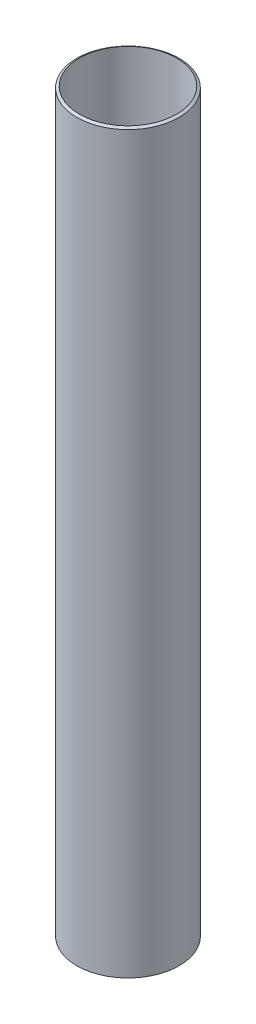
from build123d import *


with BuildPart() as part:
    # Sketch2 → Revolve1 (revolve)
    with BuildSketch(Plane.XY):
        Polygon((-63.5, 1.833087105), (-63.5, 912.566912895), (-60.325, 914.4), (-60.325, 0), align=None)
    revolve(axis=Axis((0, 819.187021794, 0), (0, -1, 0)))


solid = part.part
